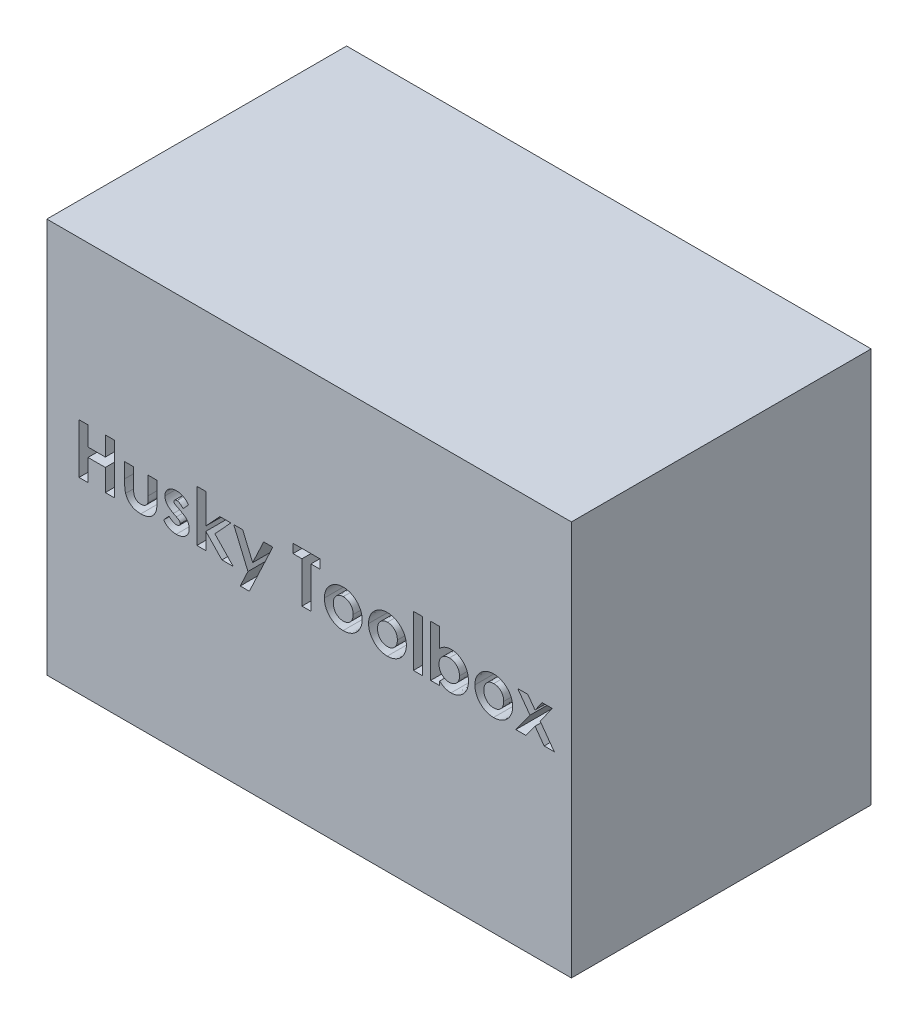
from build123d import *

# Parameters (mm, degrees)
SKETCH1_W           = 1066.8
SKETCH1_H           = 609.6
BOSS_EXTRUDE1_DEPTH = 803.275
SKETCH2_W           = 18.235897436
SKETCH2_H           = 104.205128205
CUT_EXTRUDE1_DEPTH  = 76.2


with BuildPart() as part:
    # Sketch1 → Boss-Extrude1 (new body)
    with BuildSketch(Plane(origin=(0, 0, 0), x_dir=(1, 0, 0), z_dir=(0, 1, 0))):
        Rectangle(SKETCH1_W, SKETCH1_H)
    extrude(amount=BOSS_EXTRUDE1_DEPTH)

    # Sketch2 → Cut-Extrude1 (cut)
    with BuildSketch(Plane.XY.offset(304.8)):
        Polygon((-467.882093783, 482.6), (-449.646196347, 482.6), (-449.646196347, 443.523076923), (-414.476965577, 443.523076923), (-414.476965577, 482.6), (-396.241068142, 482.6), (-396.241068142, 381), (-414.476965577, 381), (-414.476965577, 425.287179487), (-449.646196347, 425.287179487), (-449.646196347, 381), (-467.882093783, 381), align=None)
        with BuildLine():
            Line((-375.4000425, 455.246153846), (-357.164145065, 455.246153846))
            Line((-357.164145065, 455.246153846), (-357.164145065, 419.608814103))
            add(Edge.make_bspline(
                [(-357.164145065, 419.608814103), (-357.162525707, 418.774273627), (-357.159417764, 417.172586653), (-357.072933887, 414.87225059), (-356.951579907, 412.768698591), (-356.800138351, 410.85945019), (-356.574102125, 409.149097763), (-356.313152828, 407.640906423), (-356.017320511, 406.324009467), (-355.536259804, 404.856152232), (-354.783631639, 403.249864802), (-353.64702989, 401.544602062), (-352.270273655, 400.070048407), (-350.671963842, 398.813117931), (-348.835777783, 397.822629117), (-346.787013305, 397.151389962), (-344.551448045, 396.700247459), (-342.994380186, 396.654539006), (-342.184657885, 396.630769231)],
                knots=[0, 0, 0, 0, 1.267339619, 2.432334223, 3.495366327, 4.467371443, 5.340232306, 6.114347373, 6.791623365, 7.387877112, 8.457231658, 9.474542289, 10.487879852, 11.508108106, 12.54995813, 13.638205937, 14.771795776, 16, 16, 16, 16], degree=3))
            add(Edge.make_bspline(
                [(-342.184657885, 396.630769231), (-341.375654139, 396.657899066), (-339.814559449, 396.710250174), (-337.564120106, 397.118498038), (-335.51052999, 397.818044352), (-333.632697412, 398.766896366), (-331.985999769, 400.036773171), (-330.552287479, 401.549921474), (-329.34513537, 403.330750214), (-328.765043116, 404.659197429), (-328.46702968, 405.341666667)],
                knots=[0, 0, 0, 0, 1.116871431, 2.155171802, 3.144773418, 4.104381479, 5.046960687, 6.001340237, 6.973219418, 8, 8, 8, 8], degree=3))
            add(Edge.make_bspline(
                [(-328.46702968, 405.341666667), (-328.357668762, 405.644825621), (-328.116267146, 406.314014055), (-327.901414931, 407.468456184), (-327.67016997, 408.82993376), (-327.487246993, 410.426192545), (-327.383742718, 412.247346757), (-327.272848484, 414.295691681), (-327.216334791, 416.569187285), (-327.20900602, 418.163760351), (-327.205170706, 418.998237179)],
                knots=[0, 0, 0, 0, 0.56094539, 1.238222264, 2.041156151, 2.969685991, 4.036367568, 5.220421584, 6.545382566, 8, 8, 8, 8], degree=3))
            Line((-327.205170706, 418.998237179), (-327.205170706, 455.246153846))
            Line((-327.205170706, 455.246153846), (-308.96927327, 455.246153846))
            Line((-308.96927327, 455.246153846), (-308.96927327, 424.045673077))
            add(Edge.make_bspline(
                [(-308.96927327, 424.045673077), (-308.972430797, 422.498687074), (-308.978484734, 419.532646688), (-309.15198684, 415.277958136), (-309.391439408, 411.409597034), (-309.699808249, 407.916912562), (-310.144129648, 404.798455232), (-310.689557842, 402.061537917), (-311.292975556, 399.68807469), (-311.846332096, 398.281781328), (-312.103568142, 397.628044872)],
                knots=[0, 0, 0, 0, 1.388070971, 2.661352173, 3.82033814, 4.865898334, 5.806910977, 6.645039373, 7.370126333, 8, 8, 8, 8], degree=3))
            add(Edge.make_bspline(
                [(-312.103568142, 397.628044872), (-312.433278496, 396.924422468), (-313.084098412, 395.535532291), (-314.213391943, 393.56083805), (-315.430833628, 391.689971702), (-316.794349805, 389.966971599), (-318.276106878, 388.374326219), (-319.834220235, 386.87583086), (-321.538859205, 385.532506509), (-323.345816208, 384.309785646), (-325.280304814, 383.224386644), (-327.32907519, 382.262539284), (-329.51426756, 381.479760465), (-331.816933713, 380.816245009), (-334.24768744, 380.321427404), (-336.801632258, 379.946640821), (-339.481569246, 379.752949687), (-341.309236633, 379.716243691), (-342.245715577, 379.697435897)],
                knots=[0, 0, 0, 0, 0.997311338, 1.968606903, 2.91805772, 3.860812155, 4.785445165, 5.709667791, 6.633356648, 7.568312411, 8.508286151, 9.478643871, 10.470653671, 11.485274776, 12.552984541, 13.653035246, 14.797438149, 16, 16, 16, 16], degree=3))
            add(Edge.make_bspline(
                [(-342.245715577, 379.697435897), (-343.257375993, 379.70949222), (-345.236852369, 379.733082355), (-348.1288397, 380.021969064), (-350.884942508, 380.395750909), (-353.474389074, 381.031248555), (-355.933342226, 381.767504367), (-358.233571792, 382.707162623), (-360.384477085, 383.811934489), (-362.390290303, 385.075270267), (-364.23545509, 386.508747089), (-365.961000745, 388.050401505), (-367.511219242, 389.761571057), (-368.936718905, 391.589414161), (-370.221590355, 393.550753346), (-371.366471323, 395.638614688), (-372.372331584, 397.862494834), (-372.909007929, 399.421117273), (-373.181613013, 400.212820513)],
                knots=[0, 0, 0, 0, 1.211240017, 2.369985978, 3.478996442, 4.539426614, 5.559871561, 6.551301256, 7.510778031, 8.453136967, 9.386094087, 10.30661716, 11.221130616, 12.147659962, 13.080758632, 14.026335491, 14.997475882, 16, 16, 16, 16], degree=3))
            add(Edge.make_bspline(
                [(-373.181613013, 400.212820513), (-373.36759309, 400.827687554), (-373.76823753, 402.152254499), (-374.200810772, 404.353530156), (-374.546798584, 406.890623605), (-374.883364586, 409.766030434), (-375.118159181, 412.984571264), (-375.271623716, 416.541134626), (-375.37531496, 420.442675371), (-375.391557156, 423.156872626), (-375.4000425, 424.574839744)],
                knots=[0, 0, 0, 0, 0.627914866, 1.352675004, 2.190563461, 3.132055958, 4.183353232, 5.345633452, 6.613289997, 8, 8, 8, 8], degree=3))
            Line((-375.4000425, 424.574839744), (-375.4000425, 455.246153846))
        make_face()
        with BuildLine():
            Line((-245.143632244, 443.787660256), (-256.296837372, 431.8))
            add(Edge.make_bspline(
                [(-256.296837372, 431.8), (-256.853770336, 432.416276519), (-257.918972125, 433.594980052), (-259.549693112, 435.201816403), (-261.156129489, 436.539836419), (-262.708345429, 437.663828997), (-264.238042727, 438.525796945), (-265.732506161, 439.145963578), (-267.192452775, 439.539654578), (-268.160167109, 439.590616389), (-268.630491218, 439.615384615)],
                knots=[0, 0, 0, 0, 1.327646587, 2.539285, 3.655602211, 4.666613517, 5.598770349, 6.454635452, 7.248928967, 8, 8, 8, 8], degree=3))
            add(Edge.make_bspline(
                [(-268.630491218, 439.615384615), (-269.106411975, 439.600880181), (-270.017652173, 439.5731087), (-271.303616285, 439.334899061), (-272.433421786, 438.922514268), (-273.389437341, 438.360395366), (-274.157517158, 437.667922611), (-274.695285658, 436.875750115), (-275.05640215, 436.00851631), (-275.086950267, 435.392486633), (-275.102606603, 435.076762821)],
                knots=[0, 0, 0, 0, 1.295068245, 2.479652818, 3.543291146, 4.55379989, 5.481948265, 6.332409746, 7.145336708, 8, 8, 8, 8], degree=3))
            add(Edge.make_bspline(
                [(-275.102606603, 435.076762821), (-275.049561499, 434.598304786), (-274.93949907, 433.605559946), (-274.183522822, 432.454124043), (-273.183311652, 431.604733351), (-272.030357382, 430.814326538), (-270.468958823, 429.93056709), (-269.284442242, 429.325431177), (-268.630491218, 428.991346154)],
                knots=[0, 0, 0, 0, 0.916701701, 1.902049539, 2.5493345, 3.440293453, 4.586830489, 6, 6, 6, 6], degree=3))
            Line((-268.630491218, 428.991346154), (-262.036260449, 425.653525641))
            add(Edge.make_bspline(
                [(-262.036260449, 425.653525641), (-261.197348212, 425.227553258), (-259.569700886, 424.401086817), (-257.281381225, 423.067472235), (-255.167852702, 421.774837207), (-253.271512085, 420.450060905), (-251.580752549, 419.116159118), (-250.107583478, 417.759941323), (-248.816273099, 416.424402184), (-247.376280767, 414.633809319), (-245.935856254, 412.248885313), (-244.734989576, 409.147402778), (-243.969211496, 405.826396923), (-243.884486973, 403.527802134), (-243.841068142, 402.349839744)],
                knots=[0, 0, 0, 0, 1.076693506, 2.088987655, 3.030641824, 3.911722491, 4.735175175, 5.493635918, 6.202154166, 6.859459289, 8.120623445, 9.372284821, 10.653373066, 12, 12, 12, 12], degree=3))
            add(Edge.make_bspline(
                [(-243.841068142, 402.349839744), (-243.867228266, 401.555136226), (-243.918430573, 399.999690543), (-244.242120756, 397.710222788), (-244.823552148, 395.533277934), (-245.58871498, 393.43492175), (-246.619366384, 391.453098916), (-247.870627691, 389.578202241), (-249.322741015, 387.785615357), (-251.014095068, 386.13665914), (-252.866945146, 384.599849995), (-254.926700686, 383.307283145), (-257.102288259, 382.170819803), (-259.451183442, 381.283343121), (-261.940428313, 380.563835327), (-264.591360841, 380.065234453), (-267.394985863, 379.751452147), (-269.314823558, 379.715747053), (-270.299401475, 379.697435897)],
                knots=[0, 0, 0, 0, 0.976600749, 1.911466839, 2.833459288, 3.740827163, 4.650527853, 5.570709661, 6.506801416, 7.479409329, 8.468875524, 9.458587492, 10.461481786, 11.480119772, 12.538142914, 13.641687514, 14.790552763, 16, 16, 16, 16], degree=3))
            add(Edge.make_bspline(
                [(-270.299401475, 379.697435897), (-271.603882656, 379.738976375), (-274.164464364, 379.820516675), (-277.904008573, 380.388514764), (-281.435131077, 381.371729021), (-284.760737027, 382.749086426), (-287.901195281, 384.504217347), (-290.811656578, 386.681950612), (-293.542576417, 389.225547087), (-295.131453952, 391.176367126), (-295.943632244, 392.173557692)],
                knots=[0, 0, 0, 0, 1.056901255, 2.07460411, 3.05625841, 4.019970729, 4.984811261, 5.963335951, 6.958928997, 8, 8, 8, 8], degree=3))
            Line((-295.943632244, 392.173557692), (-284.892189936, 404.446153846))
            add(Edge.make_bspline(
                [(-284.892189936, 404.446153846), (-284.353726347, 403.878213229), (-283.284700015, 402.750665357), (-281.482753611, 401.263841039), (-279.576166696, 399.908710061), (-277.5437144, 398.770842188), (-275.510851422, 397.852065081), (-273.560487115, 397.162853726), (-271.729378261, 396.729730923), (-270.538838488, 396.66262188), (-269.973760449, 396.630769231)],
                knots=[0, 0, 0, 0, 1.087861918, 2.159761696, 3.243809206, 4.338405912, 5.394481878, 6.343674753, 7.213841449, 8, 8, 8, 8], degree=3))
            add(Edge.make_bspline(
                [(-269.973760449, 396.630769231), (-269.40898828, 396.647125411), (-268.323340299, 396.678566503), (-266.780353407, 397.00561557), (-265.412733021, 397.555433368), (-264.252940016, 398.317769693), (-263.288255228, 399.192815372), (-262.608529452, 400.187309916), (-262.159058782, 401.241852654), (-262.104430886, 401.979148801), (-262.076965577, 402.349839744)],
                knots=[0, 0, 0, 0, 1.255011871, 2.412479185, 3.488767498, 4.514443302, 5.48617286, 6.365347346, 7.178144445, 8, 8, 8, 8], degree=3))
            add(Edge.make_bspline(
                [(-262.076965577, 402.349839744), (-262.101472778, 402.698923307), (-262.151790785, 403.415659155), (-262.550160059, 404.47361255), (-263.175607662, 405.521156162), (-264.043069359, 406.561243496), (-265.164087837, 407.585435475), (-266.53465125, 408.585528661), (-268.123140659, 409.614879252), (-269.296489352, 410.229263714), (-269.912702757, 410.551923077)],
                knots=[0, 0, 0, 0, 0.704666567, 1.446816302, 2.258757648, 3.165368109, 4.175243826, 5.322435858, 6.59381024, 8, 8, 8, 8], degree=3))
            Line((-269.912702757, 410.551923077), (-275.957414295, 413.604807692))
            add(Edge.make_bspline(
                [(-275.957414295, 413.604807692), (-277.328596176, 414.340090271), (-279.960751283, 415.751557138), (-283.518441033, 418.171922857), (-286.529511798, 420.748450339), (-288.996417356, 423.467297589), (-290.962052588, 426.320834874), (-292.333215041, 429.345393303), (-293.195801466, 432.512299382), (-293.290699776, 434.677864116), (-293.338504039, 435.76875)],
                knots=[0, 0, 0, 0, 1.255999728, 2.41104856, 3.467751088, 4.449286722, 5.368722015, 6.253902015, 7.120417131, 8, 8, 8, 8], degree=3))
            add(Edge.make_bspline(
                [(-293.338504039, 435.76875), (-293.321925919, 436.475759698), (-293.289380376, 437.863734605), (-292.942913518, 439.902071943), (-292.419476444, 441.861432308), (-291.680850346, 443.744927337), (-290.734683212, 445.554425956), (-289.575464323, 447.281897766), (-288.189051315, 448.924202203), (-286.619829108, 450.476049044), (-284.878727813, 451.889382777), (-283.015493357, 453.141926959), (-281.035636838, 454.208861693), (-278.922909841, 455.059497958), (-276.704166261, 455.736551484), (-274.364760039, 456.196764176), (-271.914672148, 456.489461057), (-270.239202779, 456.528685779), (-269.38353609, 456.548717949)],
                knots=[0, 0, 0, 0, 0.959035663, 1.882742823, 2.798841253, 3.708806893, 4.623422363, 5.566085165, 6.527241613, 7.536786942, 8.55815439, 9.567237405, 10.580975912, 11.605536372, 12.654523293, 13.725718749, 14.838518481, 16, 16, 16, 16], degree=3))
            add(Edge.make_bspline(
                [(-269.38353609, 456.548717949), (-268.200571367, 456.50976987), (-265.852595058, 456.432464805), (-262.389791794, 455.806911748), (-259.045083027, 454.755501446), (-255.827845541, 453.306833878), (-252.779463052, 451.486270451), (-249.966970971, 449.275491579), (-247.371335322, 446.72893666), (-245.893573786, 444.77782155), (-245.143632244, 443.787660256)],
                knots=[0, 0, 0, 0, 0.996590028, 1.978055413, 2.954661574, 3.945146934, 4.945404762, 5.939399542, 6.954276554, 8, 8, 8, 8], degree=3))
        make_face()
        Polygon((-228.210298911, 485.205128205), (-209.974401475, 485.205128205), (-209.974401475, 424.432371795), (-181.602927116, 455.246153846), (-159.072638654, 455.246153846), (-191.657093783, 419.853044872), (-154.411901475, 381), (-177.369593783, 381), (-209.974401475, 415.009134615), (-209.974401475, 381), (-228.210298911, 381), align=None)
        Polygon((-153.353568142, 455.246153846), (-135.097318142, 455.246153846), (-114.826164295, 407.478685897), (-92.397638654, 455.246153846), (-73.856452757, 455.246153846), (-121.583215577, 353.646153846), (-140.124401475, 353.646153846), (-124.432574552, 387.044711538), align=None)
        Polygon((-32.825683526, 482.6), (21.882008782, 482.6), (21.882008782, 464.364102564), (3.646111346, 464.364102564), (3.646111346, 381), (-14.58978609, 381), (-14.58978609, 464.364102564), (-32.825683526, 464.364102564), align=None)
        with BuildLine():
            add(Edge.make_bspline(
                [(68.977842115, 456.548717949), (69.840000141, 456.533375257), (71.547463696, 456.502989774), (74.090517354, 456.250058382), (76.589112574, 455.837390386), (79.057610941, 455.303057365), (81.473090149, 454.554376883), (83.848219087, 453.656450411), (86.204234427, 452.625525813), (88.48266034, 451.398364947), (90.69995675, 450.067397071), (92.802085706, 448.599230298), (94.771590478, 447.005396577), (96.645031775, 445.3228502), (98.335104212, 443.478338586), (99.949812485, 441.560738038), (101.401917838, 439.501347624), (102.746358221, 437.350349924), (103.943303824, 435.120183735), (104.982630949, 432.82636289), (105.884669177, 430.500601083), (106.590947033, 428.114568946), (107.175679998, 425.699729478), (107.544688059, 423.226490632), (107.807027205, 420.720258779), (107.836443738, 419.032857257), (107.851239551, 418.184134615)],
                knots=[0, 0, 0, 0, 1.022364134, 2.024744242, 3.027414945, 4.024939316, 5.017584196, 6.023349371, 7.035562955, 8.064994934, 9.090267829, 10.101425541, 11.102933353, 12.093946398, 13.084502048, 14.067315274, 15.065326281, 16.070028806, 17.074376865, 18.064572984, 19.055292013, 20.030201733, 21.013838017, 21.999348303, 22.993720005, 24, 24, 24, 24], degree=3))
            add(Edge.make_bspline(
                [(107.851239551, 418.184134615), (107.835625021, 417.328781327), (107.804579797, 415.628145087), (107.554179165, 413.098339026), (107.13993161, 410.61346969), (106.603547795, 408.158898289), (105.857669087, 405.766033403), (104.98618943, 403.39960327), (103.916413869, 401.091863213), (102.73369816, 398.817637962), (101.380613592, 396.643851025), (99.9297652, 394.563830488), (98.321820121, 392.632145062), (96.645277183, 390.788887806), (94.82061416, 389.096389433), (92.876956084, 387.527168278), (90.831129636, 386.062039917), (88.668423164, 384.735379018), (86.416537323, 383.569689396), (84.113449752, 382.518725075), (81.745693275, 381.643722235), (79.318168085, 380.930181514), (76.829401978, 380.377704796), (74.284889503, 380.002400789), (71.690110595, 379.741381179), (69.941850741, 379.712178628), (69.059252371, 379.697435897)],
                knots=[0, 0, 0, 0, 1.012026251, 2.012137606, 3.004615893, 3.992048833, 4.982446996, 5.968083444, 6.973977695, 7.990229942, 8.999482246, 10.001782172, 10.988562221, 11.971415814, 12.948383116, 13.930088534, 14.925840678, 15.924049238, 16.929462851, 17.924729459, 18.917889337, 19.913673841, 20.916777188, 21.931792057, 22.95587778, 24, 24, 24, 24], degree=3))
            add(Edge.make_bspline(
                [(69.059252371, 379.697435897), (67.768713581, 379.735315756), (65.225041976, 379.809977533), (61.478815086, 380.321391176), (57.879927697, 381.201668138), (54.422515465, 382.428754813), (51.102087124, 384.001220663), (47.94762072, 385.947385939), (44.927737906, 388.228936226), (42.094745334, 390.826587663), (39.499340354, 393.676446514), (37.231941841, 396.718653475), (35.306737014, 399.907610972), (33.725457977, 403.246955497), (32.505033013, 406.741266188), (31.623677958, 410.380096281), (31.111639055, 414.173673997), (31.037608739, 416.751140129), (30.9999575, 418.062019231)],
                knots=[0, 0, 0, 0, 1.029999031, 2.030143771, 3.011211297, 3.982305373, 4.953580601, 5.938004764, 6.935448627, 7.970290061, 9.001484052, 10.007591832, 10.993831261, 11.969999897, 12.951306496, 13.942897864, 14.953773953, 16, 16, 16, 16], degree=3))
            add(Edge.make_bspline(
                [(30.9999575, 418.062019231), (31.03892175, 419.461750752), (31.115505205, 422.212895032), (31.723611537, 426.243384096), (32.694691747, 430.102386361), (34.088616221, 433.779106977), (35.869232138, 437.280327155), (38.04296063, 440.598662438), (40.620544399, 443.734864464), (42.594457423, 445.631746965), (43.598194679, 446.596314103)],
                knots=[0, 0, 0, 0, 1.043912699, 2.05178951, 3.033892, 4.007821512, 4.978932272, 5.95884105, 6.962068106, 8, 8, 8, 8], degree=3))
            add(Edge.make_bspline(
                [(43.598194679, 446.596314103), (44.519223944, 447.395831764), (46.336224017, 448.9731146), (49.288251119, 450.973639295), (52.310793761, 452.701482303), (55.440078416, 454.122090618), (58.684828725, 455.19320637), (62.028417183, 455.972882802), (65.470148537, 456.451782915), (67.80266903, 456.516242067), (68.977842115, 456.548717949)],
                knots=[0, 0, 0, 0, 1.048115528, 2.067714963, 3.060638214, 4.039924844, 5.017819947, 5.994373833, 6.98952318, 8, 8, 8, 8], degree=3))
        make_face()
        with BuildLine():
            add(Edge.make_bspline(
                [(69.384893397, 439.615384615), (68.678849491, 439.591918054), (67.288994463, 439.545723877), (65.243091346, 439.297812062), (63.308054632, 438.789695509), (61.445450887, 438.143510317), (59.688229752, 437.279328666), (57.988267202, 436.268036986), (56.433957546, 435.002529892), (54.950082774, 433.614361192), (53.603055236, 432.072837104), (52.455259862, 430.393347765), (51.429679269, 428.640146915), (50.652033512, 426.749047687), (50.008457309, 424.771739312), (49.572892651, 422.676274499), (49.269770064, 420.486060735), (49.247267507, 418.985749292), (49.235854935, 418.224839744)],
                knots=[0, 0, 0, 0, 1.030650113, 2.02884584, 2.99876339, 3.944280128, 4.900564847, 5.851248946, 6.823638398, 7.81794922, 8.81432732, 9.802856497, 10.78262424, 11.771747962, 12.779760563, 13.812642396, 14.89064281, 16, 16, 16, 16], degree=3))
            add(Edge.make_bspline(
                [(49.235854935, 418.224839744), (49.249209195, 417.437096695), (49.275307531, 415.897604184), (49.545561268, 413.649738096), (49.991218586, 411.516528077), (50.624357969, 409.501269478), (51.420637648, 407.589497019), (52.397580475, 405.791937037), (53.565496987, 404.119397562), (54.889630843, 402.573938209), (56.33950086, 401.17110765), (57.928155079, 399.967250956), (59.58906664, 398.921259268), (61.360511957, 398.081166498), (63.217331436, 397.432546721), (65.165037205, 396.954989795), (67.213864456, 396.697705274), (68.61084085, 396.653388048), (69.323835705, 396.630769231)],
                knots=[0, 0, 0, 0, 1.141730614, 2.231293227, 3.276944405, 4.297399982, 5.28939179, 6.275415646, 7.257752684, 8.24146775, 9.222424823, 10.176631434, 11.126518621, 12.063689483, 13.012557477, 13.974037417, 14.965980454, 16, 16, 16, 16], degree=3))
            add(Edge.make_bspline(
                [(69.323835705, 396.630769231), (70.037187163, 396.6508311), (71.435770134, 396.690164011), (73.487003349, 396.984705395), (75.444655534, 397.448255479), (77.317333704, 398.102457704), (79.089897081, 398.960532209), (80.769131195, 400.01152806), (82.36980848, 401.232129318), (83.839135895, 402.661428624), (85.199264181, 404.211707711), (86.392015338, 405.893076403), (87.388723187, 407.690636847), (88.206202096, 409.593078771), (88.840582649, 411.59778729), (89.278862023, 413.71221365), (89.582146674, 415.929805087), (89.604140313, 417.450380281), (89.615342115, 418.224839744)],
                knots=[0, 0, 0, 0, 1.031504075, 2.022346795, 2.991027682, 3.937587355, 4.885570121, 5.833146507, 6.798790848, 7.791235734, 8.792807298, 9.778388351, 10.766749885, 11.760164525, 12.768777521, 13.802286646, 14.880660483, 16, 16, 16, 16], degree=3))
            add(Edge.make_bspline(
                [(89.615342115, 418.224839744), (89.601817972, 418.999028529), (89.575279218, 420.518238071), (89.305006223, 422.738828767), (88.86372246, 424.84642071), (88.222416974, 426.832014655), (87.430870269, 428.718263084), (86.453252185, 430.495510994), (85.279575879, 432.155004985), (83.949005037, 433.688516366), (82.477400562, 435.071662023), (80.916329213, 436.305092181), (79.230094087, 437.325233682), (77.45032997, 438.166194442), (75.572301757, 438.813193701), (73.598117847, 439.29345707), (71.521727977, 439.547080541), (70.104615755, 439.592378637), (69.384893397, 439.615384615)],
                knots=[0, 0, 0, 0, 1.123894411, 2.205445421, 3.243160173, 4.246488011, 5.231014757, 6.210004299, 7.185865357, 8.177612767, 9.153374344, 10.115157457, 11.061423229, 12.009021698, 12.96873347, 13.94135618, 14.954456845, 16, 16, 16, 16], degree=3))
        make_face(mode=Mode.SUBTRACT)
        with BuildLine():
            add(Edge.make_bspline(
                [(158.854765192, 456.548717949), (159.716923218, 456.533375257), (161.424386772, 456.502989774), (163.967440431, 456.250058382), (166.466035651, 455.837390386), (168.934534018, 455.303057365), (171.350013226, 454.554376883), (173.725142164, 453.656450411), (176.081157504, 452.625525813), (178.359583417, 451.398364947), (180.576879827, 450.067397071), (182.679008783, 448.599230298), (184.648513555, 447.005396577), (186.521954852, 445.3228502), (188.212027289, 443.478338586), (189.826735562, 441.560738038), (191.278840915, 439.501347624), (192.623281298, 437.350349924), (193.820226901, 435.120183735), (194.859554026, 432.82636289), (195.761592253, 430.500601083), (196.467870109, 428.114568946), (197.052603075, 425.699729478), (197.421611136, 423.226490632), (197.683950282, 420.720258779), (197.713366815, 419.032857257), (197.728162628, 418.184134615)],
                knots=[0, 0, 0, 0, 1.022364134, 2.024744242, 3.027414945, 4.024939316, 5.017584196, 6.023349371, 7.035562955, 8.064994934, 9.090267829, 10.101425541, 11.102933353, 12.093946398, 13.084502048, 14.067315274, 15.065326281, 16.070028806, 17.074376865, 18.064572984, 19.055292013, 20.030201733, 21.013838017, 21.999348303, 22.993720005, 24, 24, 24, 24], degree=3))
            add(Edge.make_bspline(
                [(197.728162628, 418.184134615), (197.712548098, 417.328781327), (197.681502874, 415.628145087), (197.431102242, 413.098339026), (197.016854687, 410.61346969), (196.480470872, 408.158898289), (195.734592164, 405.766033403), (194.863112507, 403.39960327), (193.793336946, 401.091863213), (192.610621237, 398.817637962), (191.257536669, 396.643851025), (189.806688277, 394.563830488), (188.198743198, 392.632145062), (186.52220026, 390.788887806), (184.697537237, 389.096389433), (182.753879161, 387.527168278), (180.708052713, 386.062039917), (178.545346241, 384.735379018), (176.293460399, 383.569689396), (173.990372829, 382.518725075), (171.622616352, 381.643722235), (169.195091162, 380.930181514), (166.706325055, 380.377704796), (164.16181258, 380.002400789), (161.567033672, 379.741381179), (159.818773818, 379.712178628), (158.936175448, 379.697435897)],
                knots=[0, 0, 0, 0, 1.012026251, 2.012137606, 3.004615893, 3.992048833, 4.982446996, 5.968083444, 6.973977695, 7.990229942, 8.999482246, 10.001782172, 10.988562221, 11.971415814, 12.948383116, 13.930088534, 14.925840678, 15.924049238, 16.929462851, 17.924729459, 18.917889337, 19.913673841, 20.916777188, 21.931792057, 22.95587778, 24, 24, 24, 24], degree=3))
            add(Edge.make_bspline(
                [(158.936175448, 379.697435897), (157.645636658, 379.735315756), (155.101965053, 379.809977533), (151.355738163, 380.321391176), (147.756850774, 381.201668138), (144.299438542, 382.428754813), (140.979010201, 384.001220663), (137.824543797, 385.947385939), (134.804660983, 388.228936226), (131.971668411, 390.826587663), (129.376263431, 393.676446514), (127.108864918, 396.718653475), (125.183660091, 399.907610972), (123.602381054, 403.246955497), (122.38195609, 406.741266188), (121.500601035, 410.380096281), (120.988562132, 414.173673997), (120.914531816, 416.751140129), (120.876880576, 418.062019231)],
                knots=[0, 0, 0, 0, 1.029999031, 2.030143771, 3.011211297, 3.982305373, 4.953580601, 5.938004764, 6.935448627, 7.970290061, 9.001484052, 10.007591832, 10.993831261, 11.969999897, 12.951306496, 13.942897864, 14.953773953, 16, 16, 16, 16], degree=3))
            add(Edge.make_bspline(
                [(120.876880576, 418.062019231), (120.915844827, 419.461750752), (120.992428282, 422.212895032), (121.600534614, 426.243384096), (122.571614823, 430.102386361), (123.965539298, 433.779106977), (125.746155215, 437.280327155), (127.919883707, 440.598662438), (130.497467476, 443.734864464), (132.4713805, 445.631746965), (133.475117756, 446.596314103)],
                knots=[0, 0, 0, 0, 1.043912699, 2.05178951, 3.033892, 4.007821512, 4.978932272, 5.95884105, 6.962068106, 8, 8, 8, 8], degree=3))
            add(Edge.make_bspline(
                [(133.475117756, 446.596314103), (134.39614702, 447.395831764), (136.213147094, 448.9731146), (139.165174196, 450.973639295), (142.187716837, 452.701482303), (145.317001493, 454.122090618), (148.561751802, 455.19320637), (151.90534026, 455.972882802), (155.347071614, 456.451782915), (157.679592107, 456.516242067), (158.854765192, 456.548717949)],
                knots=[0, 0, 0, 0, 1.048115528, 2.067714963, 3.060638214, 4.039924844, 5.017819947, 5.994373833, 6.98952318, 8, 8, 8, 8], degree=3))
        make_face()
        with BuildLine():
            add(Edge.make_bspline(
                [(159.261816474, 439.615384615), (158.555772568, 439.591918054), (157.16591754, 439.545723877), (155.120014423, 439.297812062), (153.184977709, 438.789695509), (151.322373964, 438.143510317), (149.565152829, 437.279328666), (147.865190278, 436.268036986), (146.310880623, 435.002529892), (144.827005851, 433.614361192), (143.479978313, 432.072837104), (142.332182938, 430.393347765), (141.306602346, 428.640146915), (140.528956589, 426.749047687), (139.885380385, 424.771739312), (139.449815728, 422.676274499), (139.146693141, 420.486060735), (139.124190583, 418.985749292), (139.112778012, 418.224839744)],
                knots=[0, 0, 0, 0, 1.030650113, 2.02884584, 2.99876339, 3.944280128, 4.900564847, 5.851248946, 6.823638398, 7.81794922, 8.81432732, 9.802856497, 10.78262424, 11.771747962, 12.779760563, 13.812642396, 14.89064281, 16, 16, 16, 16], degree=3))
            add(Edge.make_bspline(
                [(139.112778012, 418.224839744), (139.126132272, 417.437096695), (139.152230608, 415.897604184), (139.422484345, 413.649738096), (139.868141663, 411.516528077), (140.501281046, 409.501269478), (141.297560725, 407.589497019), (142.274503552, 405.791937037), (143.442420064, 404.119397562), (144.76655392, 402.573938209), (146.216423937, 401.17110765), (147.805078156, 399.967250956), (149.465989717, 398.921259268), (151.237435034, 398.081166498), (153.094254513, 397.432546721), (155.041960282, 396.954989795), (157.090787533, 396.697705274), (158.487763927, 396.653388048), (159.200758782, 396.630769231)],
                knots=[0, 0, 0, 0, 1.141730614, 2.231293227, 3.276944405, 4.297399982, 5.28939179, 6.275415646, 7.257752684, 8.24146775, 9.222424823, 10.176631434, 11.126518621, 12.063689483, 13.012557477, 13.974037417, 14.965980454, 16, 16, 16, 16], degree=3))
            add(Edge.make_bspline(
                [(159.200758782, 396.630769231), (159.91411024, 396.6508311), (161.312693211, 396.690164011), (163.363926426, 396.984705395), (165.321578611, 397.448255479), (167.19425678, 398.102457704), (168.966820157, 398.960532209), (170.646054272, 400.01152806), (172.246731557, 401.232129318), (173.716058972, 402.661428624), (175.076187258, 404.211707711), (176.268938415, 405.893076403), (177.265646264, 407.690636847), (178.083125173, 409.593078771), (178.717505726, 411.59778729), (179.1557851, 413.71221365), (179.459069751, 415.929805087), (179.48106339, 417.450380281), (179.492265192, 418.224839744)],
                knots=[0, 0, 0, 0, 1.031504075, 2.022346795, 2.991027682, 3.937587355, 4.885570121, 5.833146507, 6.798790848, 7.791235734, 8.792807298, 9.778388351, 10.766749885, 11.760164525, 12.768777521, 13.802286646, 14.880660483, 16, 16, 16, 16], degree=3))
            add(Edge.make_bspline(
                [(179.492265192, 418.224839744), (179.478741049, 418.999028529), (179.452202295, 420.518238071), (179.1819293, 422.738828767), (178.740645537, 424.84642071), (178.099340051, 426.832014655), (177.307793346, 428.718263084), (176.330175262, 430.495510994), (175.156498956, 432.155004985), (173.825928114, 433.688516366), (172.354323639, 435.071662023), (170.79325229, 436.305092181), (169.107017164, 437.325233682), (167.327253047, 438.166194442), (165.449224834, 438.813193701), (163.475040924, 439.29345707), (161.398651054, 439.547080541), (159.981538832, 439.592378637), (159.261816474, 439.615384615)],
                knots=[0, 0, 0, 0, 1.123894411, 2.205445421, 3.243160173, 4.246488011, 5.231014757, 6.210004299, 7.185865357, 8.177612767, 9.153374344, 10.115157457, 11.061423229, 12.009021698, 12.96873347, 13.94135618, 14.954456845, 16, 16, 16, 16], degree=3))
        make_face(mode=Mode.SUBTRACT)
        with Locations((221.174316474, 433.102564103)):
            Rectangle(SKETCH2_W, SKETCH2_H)
        with BuildLine():
            Line((265.461495961, 485.205128205), (265.461495961, 446.596314103))
            add(Edge.make_bspline(
                [(265.461495961, 446.596314103), (266.308287636, 447.393619503), (267.970584783, 448.958772457), (270.684649457, 450.982686535), (273.49609719, 452.69085343), (276.402409352, 454.123925542), (279.429743014, 455.183620577), (282.5409019, 456.00704332), (285.767765173, 456.443145363), (287.949956439, 456.513332696), (289.050117756, 456.548717949)],
                knots=[0, 0, 0, 0, 1.061187343, 2.083167259, 3.083809127, 4.061667593, 5.035358583, 6.007314429, 6.995378812, 8, 8, 8, 8], degree=3))
            add(Edge.make_bspline(
                [(289.050117756, 456.548717949), (290.246008021, 456.520073362), (292.601523804, 456.46365282), (296.06721709, 455.936886015), (299.38845833, 455.08540372), (302.577912278, 453.896502365), (305.618585884, 452.352912515), (308.544643288, 450.504755117), (311.305621184, 448.275765059), (313.902861775, 445.751060077), (316.305374021, 442.983795872), (318.395117222, 439.975192363), (320.135792208, 436.764848551), (321.611099784, 433.390717398), (322.687838513, 429.796840068), (323.517698883, 426.031426015), (323.980143652, 422.062619028), (324.044216965, 419.358916074), (324.076880576, 417.980608974)],
                knots=[0, 0, 0, 0, 0.985987466, 1.942075377, 2.884088208, 3.810275091, 4.743821533, 5.692411115, 6.659945104, 7.665215984, 8.677116751, 9.678438675, 10.680260931, 11.685531812, 12.710472044, 13.769734641, 14.863044265, 16, 16, 16, 16], degree=3))
            add(Edge.make_bspline(
                [(324.076880576, 417.980608974), (324.045966645, 416.649484999), (323.985028469, 414.025546149), (323.492686434, 410.173388), (322.65820791, 406.49348495), (321.487603657, 402.984511715), (319.999450274, 399.63537933), (318.183056351, 396.448395538), (316.027826478, 393.434692393), (313.563842559, 390.634867528), (310.871582064, 388.099417976), (308.066439603, 385.824615631), (305.092545967, 383.960593498), (302.024241848, 382.386284), (298.813189824, 381.182439994), (295.481322794, 380.339011961), (292.033917623, 379.775127997), (289.690101998, 379.723591198), (288.500598525, 379.697435897)],
                knots=[0, 0, 0, 0, 1.098553145, 2.165490463, 3.199345634, 4.208780719, 5.21409072, 6.219899742, 7.23156933, 8.267303578, 9.293302409, 10.281606823, 11.243293419, 12.184993323, 13.124258899, 14.066907486, 15.018941492, 16, 16, 16, 16], degree=3))
            add(Edge.make_bspline(
                [(288.500598525, 379.697435897), (287.441018429, 379.725761272), (285.354628183, 379.781535992), (282.279202126, 380.195204228), (279.323829347, 380.890914495), (276.451176455, 381.849259879), (273.653449012, 383.158641437), (270.881924539, 384.795851788), (268.118766099, 386.781605413), (266.365082693, 388.311857131), (265.461495961, 389.100320513)],
                knots=[0, 0, 0, 0, 0.996418773, 1.962021009, 2.912343664, 3.848616743, 4.805003894, 5.811808768, 6.872532775, 8, 8, 8, 8], degree=3))
            Line((265.461495961, 389.100320513), (265.461495961, 381))
            Line((265.461495961, 381), (247.225598525, 381))
            Line((247.225598525, 381), (247.225598525, 485.205128205))
            Line((247.225598525, 485.205128205), (265.461495961, 485.205128205))
        make_face()
        with BuildLine():
            add(Edge.make_bspline(
                [(285.10172032, 439.615384615), (284.361653199, 439.592627043), (282.910719326, 439.548009828), (280.780484138, 439.29230877), (278.762048789, 438.811205364), (276.82472461, 438.187646085), (274.993043694, 437.345939001), (273.252020813, 436.325616987), (271.616568002, 435.108960875), (270.078197292, 433.744148741), (268.695848904, 432.208732524), (267.467752276, 430.568060661), (266.44888253, 428.80076851), (265.59954355, 426.929265132), (264.958754397, 424.933301045), (264.483474493, 422.829855956), (264.225189992, 420.612483736), (264.181367218, 419.100614188), (264.158931858, 418.326602564)],
                knots=[0, 0, 0, 0, 1.060469436, 2.079096586, 3.066888298, 4.028858836, 4.99004353, 5.948472697, 6.914558426, 7.905691313, 8.889602648, 9.869280844, 10.836099585, 11.806137001, 12.808075328, 13.83377171, 14.890985086, 16, 16, 16, 16], degree=3))
            add(Edge.make_bspline(
                [(264.158931858, 418.326602564), (264.181649522, 417.539045104), (264.226233915, 415.99342968), (264.482365283, 413.728774969), (264.954309205, 411.583188157), (265.608594584, 409.55180465), (266.44348092, 407.634360888), (267.461143499, 405.82374863), (268.702758292, 404.159664613), (270.06992107, 402.583766096), (271.617803908, 401.200692484), (273.245888968, 399.960265711), (274.992620715, 398.938422789), (276.833055299, 398.110488488), (278.753227663, 397.422479617), (280.781752037, 396.957592734), (282.91038289, 396.697149582), (284.361539559, 396.653190907), (285.10172032, 396.630769231)],
                knots=[0, 0, 0, 0, 1.117193555, 2.192540452, 3.22680955, 4.227918444, 5.21468246, 6.188555072, 7.166222992, 8.154674427, 9.142376254, 10.104580718, 11.053462639, 12.005072638, 12.963662044, 13.941614018, 14.950094269, 16, 16, 16, 16], degree=3))
            add(Edge.make_bspline(
                [(285.10172032, 396.630769231), (285.814977235, 396.651598284), (287.226816783, 396.692827862), (289.292577226, 396.98051337), (291.278287664, 397.450620089), (293.168397365, 398.120692222), (294.974412167, 398.993125456), (296.712773504, 400.014016741), (298.32346661, 401.289544183), (299.869681661, 402.691457735), (301.253131046, 404.272413023), (302.494251408, 405.951969792), (303.536829395, 407.745118426), (304.364611746, 409.657805272), (305.048963015, 411.653801262), (305.516191217, 413.769640023), (305.773251611, 415.986436185), (305.818181661, 417.498294381), (305.840983141, 418.265544872)],
                knots=[0, 0, 0, 0, 1.021711385, 2.02240246, 2.981887075, 3.941027022, 4.888772411, 5.852236371, 6.822344989, 7.82661704, 8.838806642, 9.826383926, 10.814965113, 11.80282933, 12.807900643, 13.833672313, 14.900613836, 16, 16, 16, 16], degree=3))
            add(Edge.make_bspline(
                [(305.840983141, 418.265544872), (305.817817532, 419.025892693), (305.772174796, 420.523990781), (305.520378453, 422.722326965), (305.035161257, 424.807405071), (304.422512782, 426.79625867), (303.566587948, 428.662998059), (302.554543131, 430.429706476), (301.3636849, 432.10171837), (299.982238045, 433.633897593), (298.467034328, 435.028070615), (296.849580163, 436.261228152), (295.136227447, 437.310996569), (293.30364406, 438.13885787), (291.395076086, 438.820009309), (289.381356627, 439.289195422), (287.272723232, 439.548869266), (285.835107448, 439.592915046), (285.10172032, 439.615384615)],
                knots=[0, 0, 0, 0, 1.094680664, 2.156827393, 3.177782763, 4.17210342, 5.146667393, 6.126451192, 7.099203661, 8.094961544, 9.09004898, 10.058676268, 11.018205477, 11.974998356, 12.947750825, 13.930643515, 14.944335875, 16, 16, 16, 16], degree=3))
        make_face(mode=Mode.SUBTRACT)
        with BuildLine():
            add(Edge.make_bspline(
                [(375.080406217, 456.548717949), (375.942564244, 456.533375257), (377.650027798, 456.502989774), (380.193081457, 456.250058382), (382.691676677, 455.837390386), (385.160175044, 455.303057365), (387.575654251, 454.554376883), (389.950783189, 453.656450411), (392.30679853, 452.625525813), (394.585224443, 451.398364947), (396.802520853, 450.067397071), (398.904649809, 448.599230298), (400.87415458, 447.005396577), (402.747595878, 445.3228502), (404.437668314, 443.478338586), (406.052376587, 441.560738038), (407.504481941, 439.501347624), (408.848922324, 437.350349924), (410.045867926, 435.120183735), (411.085195051, 432.82636289), (411.987233279, 430.500601083), (412.693511135, 428.114568946), (413.278244101, 425.699729478), (413.647252162, 423.226490632), (413.909591307, 420.720258779), (413.93900784, 419.032857257), (413.953803653, 418.184134615)],
                knots=[0, 0, 0, 0, 1.022364134, 2.024744242, 3.027414945, 4.024939316, 5.017584196, 6.023349371, 7.035562955, 8.064994934, 9.090267829, 10.101425541, 11.102933353, 12.093946398, 13.084502048, 14.067315274, 15.065326281, 16.070028806, 17.074376865, 18.064572984, 19.055292013, 20.030201733, 21.013838017, 21.999348303, 22.993720005, 24, 24, 24, 24], degree=3))
            add(Edge.make_bspline(
                [(413.953803653, 418.184134615), (413.938189124, 417.328781327), (413.9071439, 415.628145087), (413.656743268, 413.098339026), (413.242495713, 410.61346969), (412.706111898, 408.158898289), (411.960233189, 405.766033403), (411.088753533, 403.39960327), (410.018977972, 401.091863213), (408.836262263, 398.817637962), (407.483177695, 396.643851025), (406.032329303, 394.563830488), (404.424384224, 392.632145062), (402.747841285, 390.788887806), (400.923178263, 389.096389433), (398.979520187, 387.527168278), (396.933693738, 386.062039917), (394.770987267, 384.735379018), (392.519101425, 383.569689396), (390.216013855, 382.518725075), (387.848257378, 381.643722235), (385.420732187, 380.930181514), (382.931966081, 380.377704796), (380.387453606, 380.002400789), (377.792674698, 379.741381179), (376.044414844, 379.712178628), (375.161816474, 379.697435897)],
                knots=[0, 0, 0, 0, 1.012026251, 2.012137606, 3.004615893, 3.992048833, 4.982446996, 5.968083444, 6.973977695, 7.990229942, 8.999482246, 10.001782172, 10.988562221, 11.971415814, 12.948383116, 13.930088534, 14.925840678, 15.924049238, 16.929462851, 17.924729459, 18.917889337, 19.913673841, 20.916777188, 21.931792057, 22.95587778, 24, 24, 24, 24], degree=3))
            add(Edge.make_bspline(
                [(375.161816474, 379.697435897), (373.871277683, 379.735315756), (371.327606078, 379.809977533), (367.581379189, 380.321391176), (363.9824918, 381.201668138), (360.525079568, 382.428754813), (357.204651226, 384.001220663), (354.050184822, 385.947385939), (351.030302008, 388.228936226), (348.197309437, 390.826587663), (345.601904457, 393.676446514), (343.334505943, 396.718653475), (341.409301117, 399.907610972), (339.82802208, 403.246955497), (338.607597115, 406.741266188), (337.72624206, 410.380096281), (337.214203157, 414.173673997), (337.140172841, 416.751140129), (337.102521602, 418.062019231)],
                knots=[0, 0, 0, 0, 1.029999031, 2.030143771, 3.011211297, 3.982305373, 4.953580601, 5.938004764, 6.935448627, 7.970290061, 9.001484052, 10.007591832, 10.993831261, 11.969999897, 12.951306496, 13.942897864, 14.953773953, 16, 16, 16, 16], degree=3))
            add(Edge.make_bspline(
                [(337.102521602, 418.062019231), (337.141485853, 419.461750752), (337.218069307, 422.212895032), (337.826175639, 426.243384096), (338.797255849, 430.102386361), (340.191180323, 433.779106977), (341.97179624, 437.280327155), (344.145524732, 440.598662438), (346.723108502, 443.734864464), (348.697021526, 445.631746965), (349.700758782, 446.596314103)],
                knots=[0, 0, 0, 0, 1.043912699, 2.05178951, 3.033892, 4.007821512, 4.978932272, 5.95884105, 6.962068106, 8, 8, 8, 8], degree=3))
            add(Edge.make_bspline(
                [(349.700758782, 446.596314103), (350.621788046, 447.395831764), (352.43878812, 448.9731146), (355.390815221, 450.973639295), (358.413357863, 452.701482303), (361.542642519, 454.122090618), (364.787392828, 455.19320637), (368.130981286, 455.972882802), (371.57271264, 456.451782915), (373.905233132, 456.516242067), (375.080406217, 456.548717949)],
                knots=[0, 0, 0, 0, 1.048115528, 2.067714963, 3.060638214, 4.039924844, 5.017819947, 5.994373833, 6.98952318, 8, 8, 8, 8], degree=3))
        make_face()
        with BuildLine():
            add(Edge.make_bspline(
                [(375.4874575, 439.615384615), (374.781413594, 439.591918054), (373.391558566, 439.545723877), (371.345655448, 439.297812062), (369.410618735, 438.789695509), (367.548014989, 438.143510317), (365.790793855, 437.279328666), (364.090831304, 436.268036986), (362.536521649, 435.002529892), (361.052646877, 433.614361192), (359.705619338, 432.072837104), (358.557823964, 430.393347765), (357.532243372, 428.640146915), (356.754597614, 426.749047687), (356.111021411, 424.771739312), (355.675456753, 422.676274499), (355.372334167, 420.486060735), (355.349831609, 418.985749292), (355.338419038, 418.224839744)],
                knots=[0, 0, 0, 0, 1.030650113, 2.02884584, 2.99876339, 3.944280128, 4.900564847, 5.851248946, 6.823638398, 7.81794922, 8.81432732, 9.802856497, 10.78262424, 11.771747962, 12.779760563, 13.812642396, 14.89064281, 16, 16, 16, 16], degree=3))
            add(Edge.make_bspline(
                [(355.338419038, 418.224839744), (355.351773298, 417.437096695), (355.377871634, 415.897604184), (355.648125371, 413.649738096), (356.093782689, 411.516528077), (356.726922072, 409.501269478), (357.523201751, 407.589497019), (358.500144577, 405.791937037), (359.66806109, 404.119397562), (360.992194945, 402.573938209), (362.442064963, 401.17110765), (364.030719182, 399.967250956), (365.691630743, 398.921259268), (367.463076059, 398.081166498), (369.319895539, 397.432546721), (371.267601307, 396.954989795), (373.316428558, 396.697705274), (374.713404953, 396.653388048), (375.426399807, 396.630769231)],
                knots=[0, 0, 0, 0, 1.141730614, 2.231293227, 3.276944405, 4.297399982, 5.28939179, 6.275415646, 7.257752684, 8.24146775, 9.222424823, 10.176631434, 11.126518621, 12.063689483, 13.012557477, 13.974037417, 14.965980454, 16, 16, 16, 16], degree=3))
            add(Edge.make_bspline(
                [(375.426399807, 396.630769231), (376.139751265, 396.6508311), (377.538334236, 396.690164011), (379.589567452, 396.984705395), (381.547219636, 397.448255479), (383.419897806, 398.102457704), (385.192461183, 398.960532209), (386.871695298, 400.01152806), (388.472372583, 401.232129318), (389.941699998, 402.661428624), (391.301828284, 404.211707711), (392.494579441, 405.893076403), (393.49128729, 407.690636847), (394.308766198, 409.593078771), (394.943146751, 411.59778729), (395.381426126, 413.71221365), (395.684710776, 415.929805087), (395.706704416, 417.450380281), (395.717906217, 418.224839744)],
                knots=[0, 0, 0, 0, 1.031504075, 2.022346795, 2.991027682, 3.937587355, 4.885570121, 5.833146507, 6.798790848, 7.791235734, 8.792807298, 9.778388351, 10.766749885, 11.760164525, 12.768777521, 13.802286646, 14.880660483, 16, 16, 16, 16], degree=3))
            add(Edge.make_bspline(
                [(395.717906217, 418.224839744), (395.704382075, 418.999028529), (395.67784332, 420.518238071), (395.407570325, 422.738828767), (394.966286562, 424.84642071), (394.324981077, 426.832014655), (393.533434371, 428.718263084), (392.555816287, 430.495510994), (391.382139981, 432.155004985), (390.05156914, 433.688516366), (388.579964665, 435.071662023), (387.018893316, 436.305092181), (385.332658189, 437.325233682), (383.552894072, 438.166194442), (381.674865859, 438.813193701), (379.700681949, 439.29345707), (377.62429208, 439.547080541), (376.207179858, 439.592378637), (375.4874575, 439.615384615)],
                knots=[0, 0, 0, 0, 1.123894411, 2.205445421, 3.243160173, 4.246488011, 5.231014757, 6.210004299, 7.185865357, 8.177612767, 9.153374344, 10.115157457, 11.061423229, 12.009021698, 12.96873347, 13.94135618, 14.954456845, 16, 16, 16, 16], degree=3))
        make_face(mode=Mode.SUBTRACT)
        Polygon((424.191143397, 455.246153846), (444.767585705, 455.246153846), (459.441784423, 435.015705128), (474.054925448, 455.246153846), (494.631367756, 455.246153846), (469.760534423, 420.789262821), (498.62047032, 381), (478.044028012, 381), (459.502842115, 406.562820513), (441.043066474, 381), (420.466624166, 381), (449.184092115, 420.789262821), align=None)
    extrude(amount=-CUT_EXTRUDE1_DEPTH, mode=Mode.SUBTRACT)


solid = part.part
